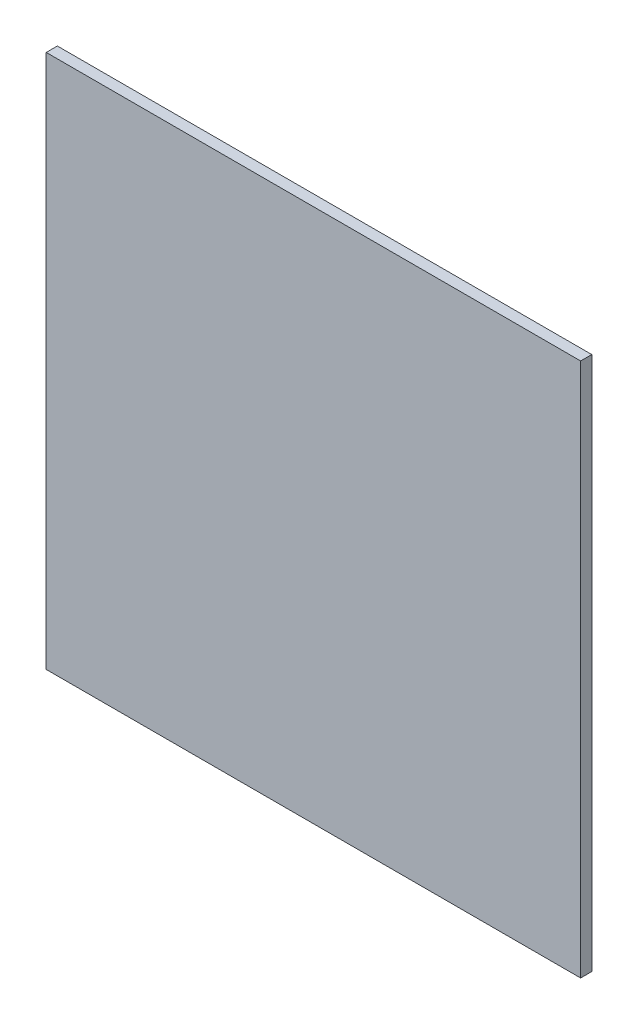
from build123d import *

# Parameters (mm, degrees)
SKETCH1_W           = 609.6
SKETCH1_H           = 609.6
BOSS_EXTRUDE1_DEPTH = 12.7


with BuildPart() as part:
    # Sketch1 → Boss-Extrude1 (new body)
    with BuildSketch(Plane.XY):
        Rectangle(SKETCH1_W, SKETCH1_H)
    extrude(amount=BOSS_EXTRUDE1_DEPTH)


solid = part.part
